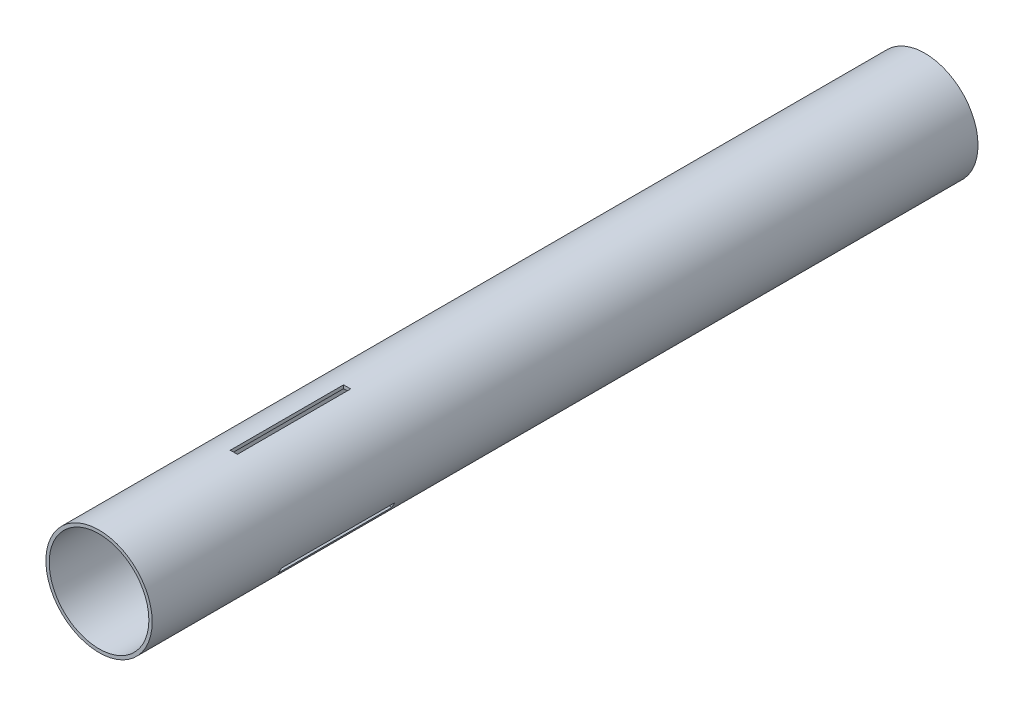
from build123d import *

# Parameters (mm, degrees)
SKETCH1_R           = 23.6982
SKETCH1_R_2         = 22.225
BOSS_EXTRUDE1_DEPTH = 368.3
CUT_EXTRUDE1_START  = -77.831769
SKETCH2_W           = 3.175
SKETCH2_H           = 50.546
CUT_EXTRUDE1_DEPTH  = 1.529969
CIRPATTERN2_COUNT   = 3


with BuildPart() as part:
    # Sketch1 → Boss-Extrude1 (new body)
    with BuildSketch(Plane.XY):
        Circle(SKETCH1_R)
        Circle(SKETCH1_R_2, mode=Mode.SUBTRACT)
    extrude(amount=BOSS_EXTRUDE1_DEPTH)

    # Sketch2 → Cut-Extrude1 (cut)
    with BuildSketch(Plane(origin=(0, 100, 0), x_dir=(1, 0, 0), z_dir=(0, 1, 0)).offset(CUT_EXTRUDE1_START)):
        with Locations((0, -282.956)):
            Rectangle(SKETCH2_W, SKETCH2_H)
    cut_extrude1 = extrude(amount=CUT_EXTRUDE1_DEPTH, mode=Mode.SUBTRACT)

    # CirPattern2: Cut-Extrude1 ×3 about axis
    cirpattern2_axis = Axis((0, 0, 0), (0, 0, 1))
    for i in range(1, CIRPATTERN2_COUNT):
        add(cut_extrude1.rotate(cirpattern2_axis, i * 360 / CIRPATTERN2_COUNT), mode=Mode.SUBTRACT)


solid = part.part
